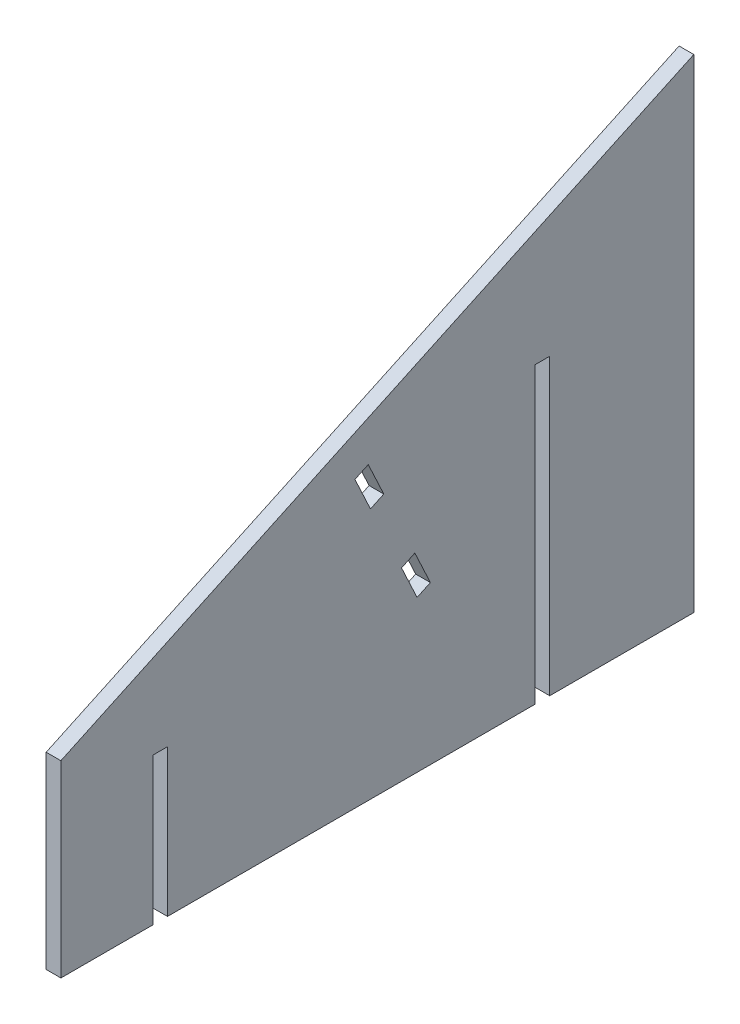
from build123d import *

# Parameters (mm, degrees)
BOSS_EXTRUDE1_DEPTH = 5.08
CUT_EXTRUDE1_DEPTH  = 6.08
LPATTERN1_COUNT     = 2
LPATTERN1_PITCH     = 38.1
SKETCH3_W           = 5.08
SKETCH3_H           = 50.8
SKETCH3_H_2         = 101.6
CUT_EXTRUDE2_DEPTH  = 6.08


with BuildPart() as part:
    # Sketch1 → Boss-Extrude1 (new body)
    with BuildSketch(Plane(origin=(0, 0, 0), x_dir=(0, 0, -1), z_dir=(1, 0, 0))):
        Polygon((0, 0), (218.692069012, 101.977786558), (218.692069012, -65.024), (0, -65.024), align=None)
    extrude(amount=BOSS_EXTRUDE1_DEPTH)

    # Sketch2 → Cut-Extrude1 (cut, through all)
    with BuildSketch(Plane(origin=(5.08, 0, 0), x_dir=(0, 0, -1), z_dir=(1, 0, 0))):
        Polygon((101.6, 33.363958498), (106.204043558, 35.510859267), (111.571295482, 24.000750372), (106.967251924, 21.853849602), align=None)
    cut_extrude1 = extrude(amount=-CUT_EXTRUDE1_DEPTH, mode=Mode.SUBTRACT)

    # LPattern1: Cut-Extrude1 ×2
    with Locations(*[Vector(0, -0.906307787, -0.422618262) * (i * LPATTERN1_PITCH) for i in range(1, LPATTERN1_COUNT)]):
        add(cut_extrude1, mode=Mode.SUBTRACT)

    # Sketch3 → Cut-Extrude2 (cut, through all)
    with BuildSketch(Plane(origin=(5.08, 0, 0), x_dir=(0, 0, -1), z_dir=(1, 0, 0))):
        with Locations((34.29, -39.624)):
            Rectangle(SKETCH3_W, SKETCH3_H)
        with Locations((166.37, -14.224)):
            Rectangle(SKETCH3_W, SKETCH3_H_2)
    extrude(amount=-CUT_EXTRUDE2_DEPTH, mode=Mode.SUBTRACT)


solid = part.part
